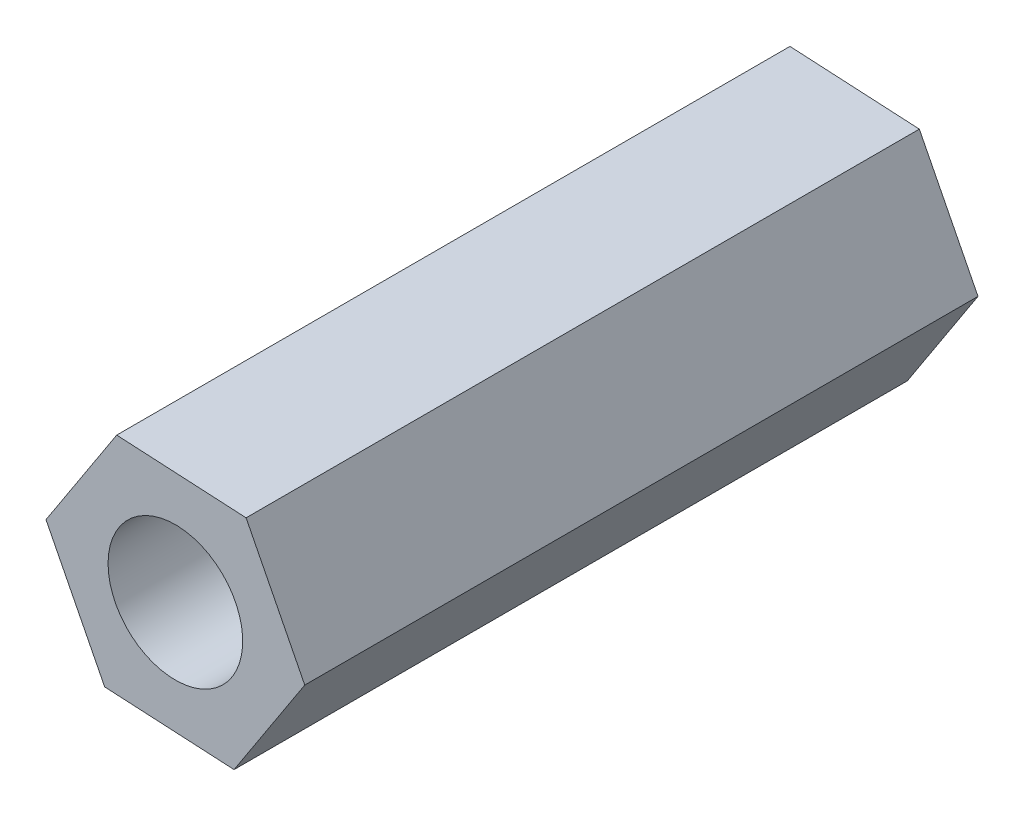
from build123d import *

# Parameters (mm, degrees)
BOSS_EXTRUDE1_DEPTH = 15
SKETCH2_R           = 1.5
CUT_EXTRUDE1_DEPTH  = 16


with BuildPart() as part:
    # Sketch1 → Boss-Extrude1 (new body)
    with BuildSketch(Plane.XY):
        Polygon((1.57545706, 2.418939517), (-1.307134542, 2.573855595), (-2.882591602, 0.154916078), (-1.57545706, -2.418939517), (1.307134542, -2.573855595), (2.882591602, -0.154916078), align=None)
    extrude(amount=BOSS_EXTRUDE1_DEPTH)

    # Sketch2 → Cut-Extrude1 (cut, through all)
    with BuildSketch(Plane(origin=(0, 0, 0), x_dir=(-1, 0, 0), z_dir=(0, 0, -1))):
        Circle(SKETCH2_R)
    extrude(amount=-CUT_EXTRUDE1_DEPTH, mode=Mode.SUBTRACT)


solid = part.part
